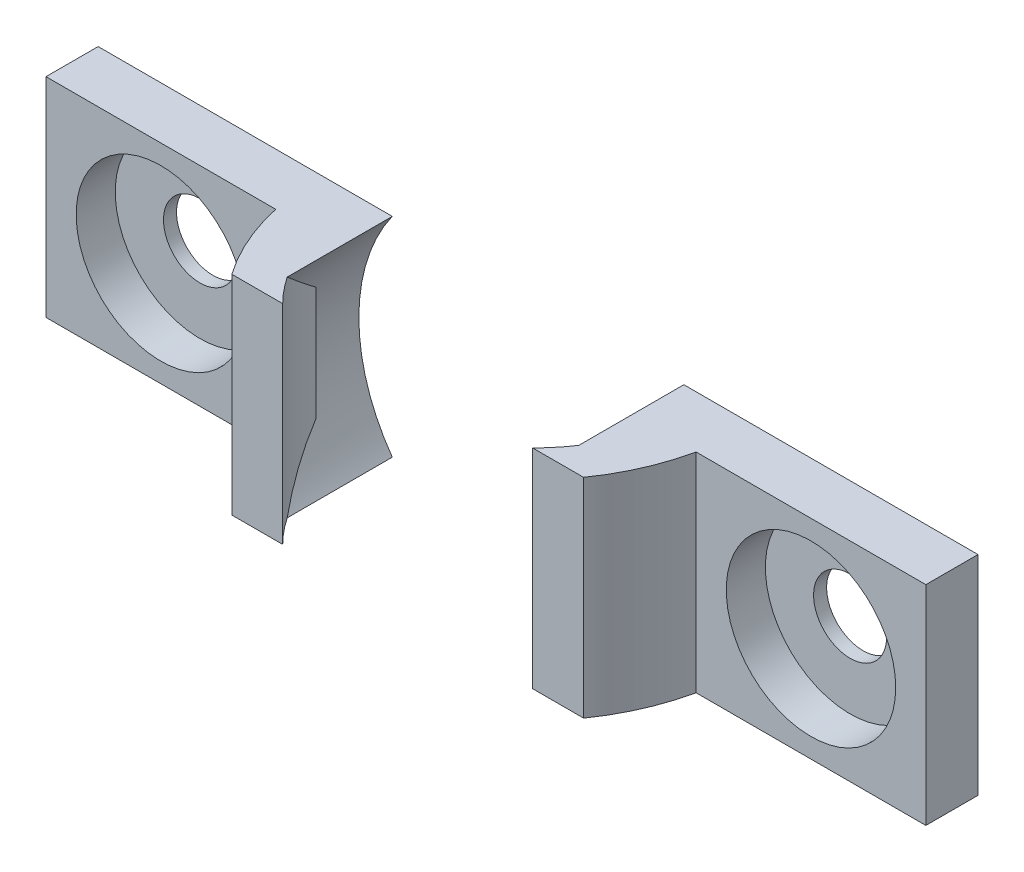
from build123d import *

# Parameters (mm, degrees)
SALIENTE_EXTRUIR1_DEPTH   = 2
SALIENTE_EXTRUIR1_2_DEPTH = 2
SALIENTE_EXTRUIR2_DEPTH   = 4
SALIENTE_EXTRUIR3_REACH   = 5
SALIENTE_EXTRUIR4_REACH   = 5
SALIENTE_EXTRUIR5_REACH   = 5
SALIENTE_EXTRUIR6_REACH   = 5
CROQUIS7_R                = 3.25
CORTAR_EXTRUIR1_DEPTH     = 1.5
CORTAR_EXTRUIR2_REACH     = 2.5
CROQUIS8_R                = 1.4


with BuildPart() as part:
    # Croquis1 → Saliente-Extruir1 (new body)
    with BuildSketch(Plane.XY):
        with BuildLine():
            Line((-68.894276555, 41.994416346), (-57.610843867, 41.994416346))
            ThreePointArc((-57.610843867, 41.994416346), (-58.894276555, 45.994416346), (-57.610843867, 49.994416346))
            Line((-57.610843867, 49.994416346), (-68.894276555, 49.994416346))
            Line((-68.894276555, 49.994416346), (-68.894276555, 41.994416346))
        make_face()
    extrude(amount=SALIENTE_EXTRUIR1_DEPTH)



with BuildPart() as body_2:
    # Croquis1 → Saliente-Extruir1 2 (new body)
    with BuildSketch(Plane.XY):
        with BuildLine():
            ThreePointArc((-45.144276555, 45.994416346), (-45.472993248, 43.893987851), (-46.427709243, 41.994416346))
            Line((-46.427709243, 41.994416346), (-35.144276555, 41.994416346))
            Line((-35.144276555, 41.994416346), (-35.144276555, 49.994416346))
            Line((-35.144276555, 49.994416346), (-46.427709243, 49.994416346))
            ThreePointArc((-46.427709243, 49.994416346), (-45.472993248, 48.094844842), (-45.144276555, 45.994416346))
        make_face()
    extrude(amount=SALIENTE_EXTRUIR1_2_DEPTH)


with BuildPart() as part_1:
    add(part.part)

    add(body_2.part)  # Saliente-Extruir2 merges body 2
    # Croquis2 → Saliente-Extruir2 (add, symmetric)
    with BuildSketch(Plane(origin=(0, 45.994416346, 0), x_dir=(-1, 0, 0), z_dir=(0, -1, 0))):
        with BuildLine():
            Line((45.50007415, -2), (43.957018807, -2))
            ThreePointArc((43.957018807, -2), (44.465042586, -3.566029122), (45.273907773, -5))
            Line((45.273907773, -5), (47.223445032, -5))
            ThreePointArc((47.223445032, -5), (46.16628602, -3.612291153), (45.50007415, -2))
        make_face()
        with BuildLine():
            Line((56.815108078, -5), (58.764645337, -5))
            ThreePointArc((58.764645337, -5), (59.573510524, -3.566029122), (60.081534303, -2))
            Line((60.081534303, -2), (58.53847896, -2))
            ThreePointArc((58.53847896, -2), (57.87226709, -3.612291153), (56.815108078, -5))
        make_face()
    extrude(amount=SALIENTE_EXTRUIR2_DEPTH, both=True)

    # Croquis3 → Saliente-Extruir3 (add, up to next)
    with BuildSketch(Plane.XY.offset(2), mode=Mode.PRIVATE) as saliente_extruir3_sk1:
        with BuildLine():
            Line((-57.610843867, 49.994416346), (-58.53847896, 49.994416346))
            Line((-58.53847896, 49.994416346), (-58.53847896, 48.177447496))
            ThreePointArc((-58.53847896, 48.177447496), (-58.142431766, 49.12053139), (-57.610843867, 49.994416346))
        make_face()
    saliente_extruir3_tool1 = extrude(saliente_extruir3_sk1.sketch, amount=SALIENTE_EXTRUIR3_REACH, mode=Mode.PRIVATE) - part_1.part
    add(saliente_extruir3_tool1.solids().sort_by_distance((-58.247136, 49.429266, 2))[0])

    # Croquis4 → Saliente-Extruir4 (add, up to next)
    with BuildSketch(Plane.XY.offset(2), mode=Mode.PRIVATE) as saliente_extruir4_sk1:
        with BuildLine():
            Line((-45.50007415, 49.994416346), (-46.427709243, 49.994416346))
            ThreePointArc((-46.427709243, 49.994416346), (-45.896121344, 49.12053139), (-45.50007415, 48.177447496))
            Line((-45.50007415, 48.177447496), (-45.50007415, 49.994416346))
        make_face()
    saliente_extruir4_tool1 = extrude(saliente_extruir4_sk1.sketch, amount=SALIENTE_EXTRUIR4_REACH, mode=Mode.PRIVATE) - part_1.part
    add(saliente_extruir4_tool1.solids().sort_by_distance((-45.791417, 49.429266, 2))[0])

    # Croquis5 → Saliente-Extruir5 (add, up to next)
    with BuildSketch(Plane.XY.offset(2), mode=Mode.PRIVATE) as saliente_extruir5_sk1:
        with BuildLine():
            Line((-58.53847896, 41.994416346), (-57.610843867, 41.994416346))
            ThreePointArc((-57.610843867, 41.994416346), (-58.142431766, 42.868301303), (-58.53847896, 43.811385197))
            Line((-58.53847896, 43.811385197), (-58.53847896, 41.994416346))
        make_face()
    saliente_extruir5_tool1 = extrude(saliente_extruir5_sk1.sketch, amount=SALIENTE_EXTRUIR5_REACH, mode=Mode.PRIVATE) - part_1.part
    add(saliente_extruir5_tool1.solids().sort_by_distance((-58.247136, 42.559567, 2))[0])

    # Croquis6 → Saliente-Extruir6 (add, up to next)
    with BuildSketch(Plane.XY.offset(2), mode=Mode.PRIVATE) as saliente_extruir6_sk1:
        with BuildLine():
            Line((-46.427709243, 41.994416346), (-45.50007415, 41.994416346))
            Line((-45.50007415, 41.994416346), (-45.50007415, 43.811385197))
            ThreePointArc((-45.50007415, 43.811385197), (-45.896121344, 42.868301303), (-46.427709243, 41.994416346))
        make_face()
    saliente_extruir6_tool1 = extrude(saliente_extruir6_sk1.sketch, amount=SALIENTE_EXTRUIR6_REACH, mode=Mode.PRIVATE) - part_1.part
    add(saliente_extruir6_tool1.solids().sort_by_distance((-45.791417, 42.559567, 2))[0])

    # Croquis7 → Cortar-Extruir1 (cut)
    with BuildSketch(Plane.XY.offset(2)):
        with Locations((-64.487905429, 45.994416346)):
            Circle(CROQUIS7_R)
        with Locations((-39.550647681, 45.994416346)):
            Circle(CROQUIS7_R)
    extrude(amount=-CORTAR_EXTRUIR1_DEPTH, mode=Mode.SUBTRACT)

    # Croquis8 → Cortar-Extruir2 (cut, up to next)
    with BuildSketch(Plane.XY.offset(0.5), mode=Mode.PRIVATE) as cortar_extruir2_sk1:
        with Locations((-64.487905429, 45.994416346)):
            Circle(CROQUIS8_R)
    cortar_extruir2_tool1 = extrude(cortar_extruir2_sk1.sketch, amount=-CORTAR_EXTRUIR2_REACH, mode=Mode.PRIVATE) & part_1.part
    add(cortar_extruir2_tool1.solids().sort_by_distance((-64.487905, 45.994416, 0.5))[0], mode=Mode.SUBTRACT)
    # Croquis8 → Cortar-Extruir2 (cut, up to next)
    with BuildSketch(Plane.XY.offset(0.5), mode=Mode.PRIVATE) as cortar_extruir2_sk2:
        with Locations((-39.550647681, 45.994416346)):
            Circle(CROQUIS8_R)
    cortar_extruir2_tool2 = extrude(cortar_extruir2_sk2.sketch, amount=-CORTAR_EXTRUIR2_REACH, mode=Mode.PRIVATE) & part_1.part
    add(cortar_extruir2_tool2.solids().sort_by_distance((-39.550648, 45.994416, 0.5))[0], mode=Mode.SUBTRACT)


solid = part_1.part
